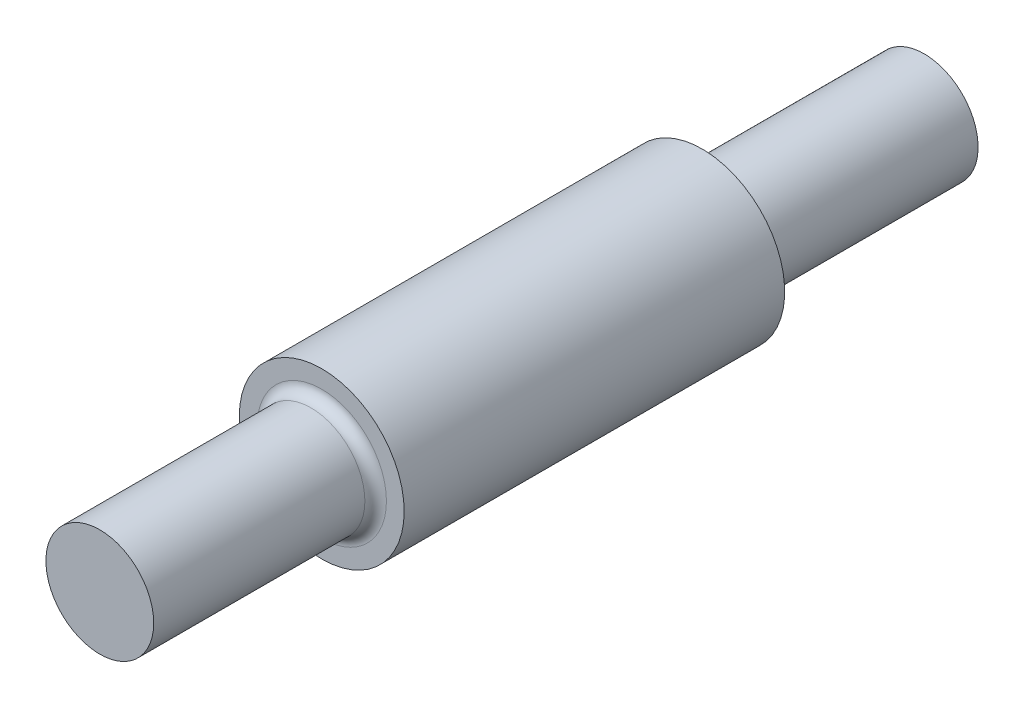
from build123d import *

# Parameters (mm, degrees)
SKETCH2_R           = 13
BOSS_EXTRUDE1_DEPTH = 130
SKETCH3_R           = 13
SKETCH3_R_2         = 8.5
CUT_EXTRUDE1_DEPTH  = 35
SKETCH4_R           = 13
SKETCH4_R_2         = 8.5
CUT_EXTRUDE2_DEPTH  = 35
FILLET1_R           = 1.7
FILLET2_R           = 1.7


with BuildPart() as part:
    # Sketch2 → Boss-Extrude1 (new body)
    with BuildSketch(Plane.XY):
        Circle(SKETCH2_R)
    extrude(amount=BOSS_EXTRUDE1_DEPTH)

    # Sketch3 → Cut-Extrude1 (cut)
    with BuildSketch(Plane.XY.offset(130)):
        Circle(SKETCH3_R)
        Circle(SKETCH3_R_2, mode=Mode.SUBTRACT)
    extrude(amount=-CUT_EXTRUDE1_DEPTH, mode=Mode.SUBTRACT)

    # Sketch4 → Cut-Extrude2 (cut)
    with BuildSketch(Plane(origin=(0, 0, 0), x_dir=(-1, 0, 0), z_dir=(0, 0, -1))):
        Circle(SKETCH4_R)
        Circle(SKETCH4_R_2, mode=Mode.SUBTRACT)
    extrude(amount=-CUT_EXTRUDE2_DEPTH, mode=Mode.SUBTRACT)

    # Fillet1
    fillet1_edges = [part.edges().sort_by_distance(p)[0] for p in [
        (-8.5, 0, 95),
    ]]
    fillet(fillet1_edges, radius=FILLET1_R)

    # Fillet2
    fillet2_edges = [part.edges().sort_by_distance(p)[0] for p in [
        (8.5, 0, 35),
    ]]
    fillet(fillet2_edges, radius=FILLET2_R)


solid = part.part
